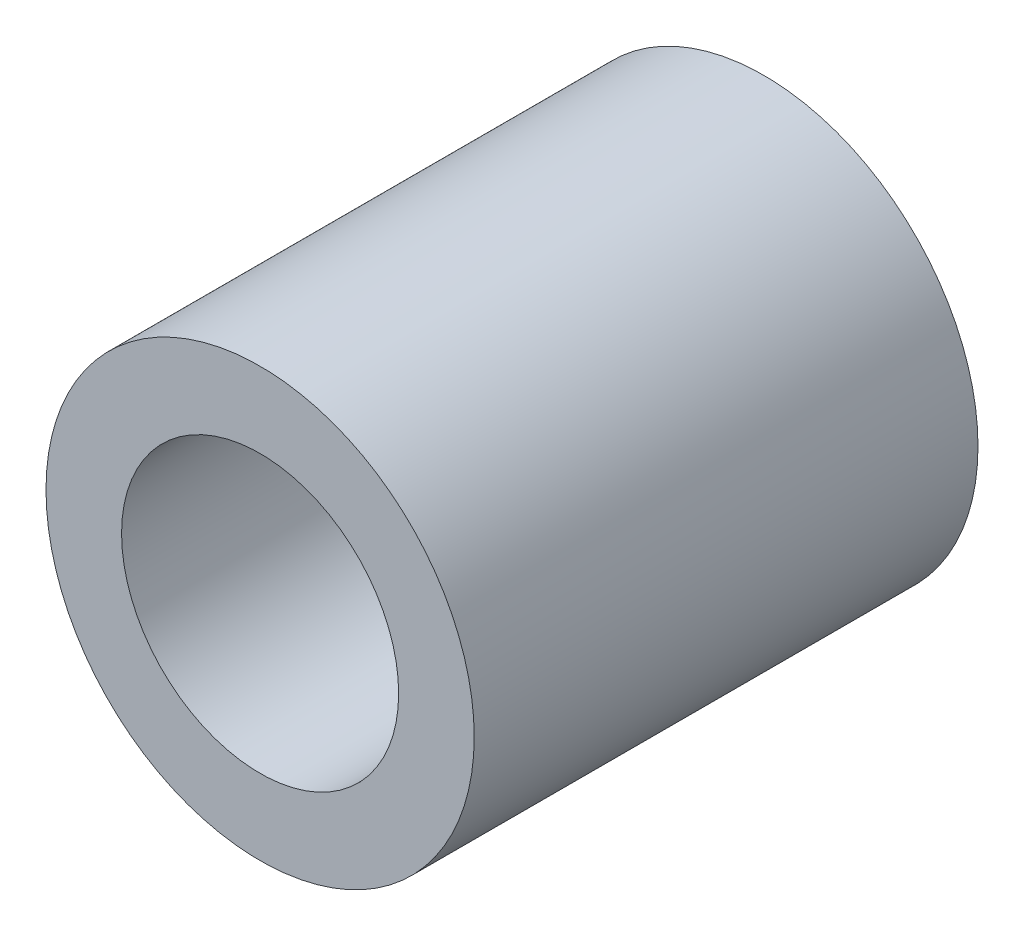
from build123d import *

# Parameters (mm, degrees)
SKETCH1_R           = 4.25
SKETCH1_R_2         = 2.75
BOSS_EXTRUDE1_DEPTH = 10


with BuildPart() as part:
    # Sketch1 → Boss-Extrude1 (new body)
    with BuildSketch(Plane.XY):
        Circle(SKETCH1_R)
        Circle(SKETCH1_R_2, mode=Mode.SUBTRACT)
    extrude(amount=BOSS_EXTRUDE1_DEPTH)


solid = part.part
